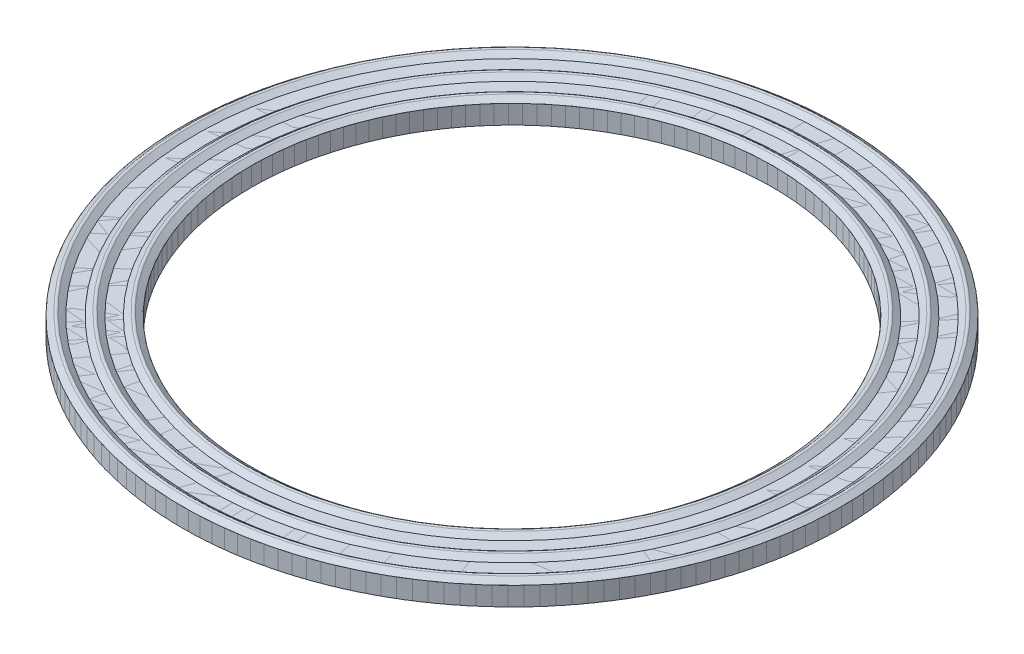
from build123d import *

# Parameters (mm, degrees)
SKETCH1_R           = 34.32175
SKETCH1_R_2         = 27.17165
BOSS_EXTRUDE1_DEPTH = 1.9558


with BuildPart() as part:
    # Sketch1 → Boss-Extrude1 (new body)
    with BuildSketch(Plane(origin=(0, 0, 0), x_dir=(1, 0, 0), z_dir=(0, 1, 0))):
        Circle(SKETCH1_R)
        Circle(SKETCH1_R_2, mode=Mode.SUBTRACT)
    extrude(amount=BOSS_EXTRUDE1_DEPTH)


with BuildPart() as body_2:
    # Sketch2 → Revolve1 (revolve)
    with BuildSketch(Plane(origin=(0, 0, 0), x_dir=(0, 0, -1), z_dir=(1, 0, 0))):
        with BuildLine():
            Line((34.32175, 1.9558), (34.32175, 0))
            Line((34.32175, 0), (32.955809933, 0))
            Line((32.955809933, 0), (32.331497753, -0.359846132))
            ThreePointArc((32.331497753, -0.359846132), (32.204656583, -0.393784055), (32.077815414, -0.359846132))
            Line((32.077815414, -0.359846132), (31.453503234, 0))
            Line((31.453503234, 0), (29.993659299, 0))
            Line((29.993659299, 0), (29.350172431, -0.324314024))
            ThreePointArc((29.350172431, -0.324314024), (29.235855876, -0.351493114), (29.121539321, -0.324314024))
            Line((29.121539321, -0.324314024), (28.478052452, 0))
            Line((28.478052452, 0), (27.17165, 0))
            Line((27.17165, 0), (27.17165, 1.9558))
            Line((27.17165, 1.9558), (27.744956445, 2.392348573))
            ThreePointArc((27.744956445, 2.392348573), (27.898834246, 2.444265366), (28.052712048, 2.392348573))
            Line((28.052712048, 2.392348573), (28.626018493, 1.9558))
            Line((28.626018493, 1.9558), (29.98624959, 1.9558))
            Line((29.98624959, 1.9558), (30.559556035, 2.392348573))
            ThreePointArc((30.559556035, 2.392348573), (30.713433836, 2.444265366), (30.867311638, 2.392348573))
            Line((30.867311638, 2.392348573), (31.440618083, 1.9558))
            Line((31.440618083, 1.9558), (32.867381507, 1.9558))
            Line((32.867381507, 1.9558), (33.440687952, 2.392348573))
            ThreePointArc((33.440687952, 2.392348573), (33.594565754, 2.444265366), (33.748443555, 2.392348573))
            Line((33.748443555, 2.392348573), (34.32175, 1.9558))
        make_face()
    revolve(axis=Axis((0, 0, 0), (0, 1, 0)))


solid = Compound([part.part, body_2.part])
